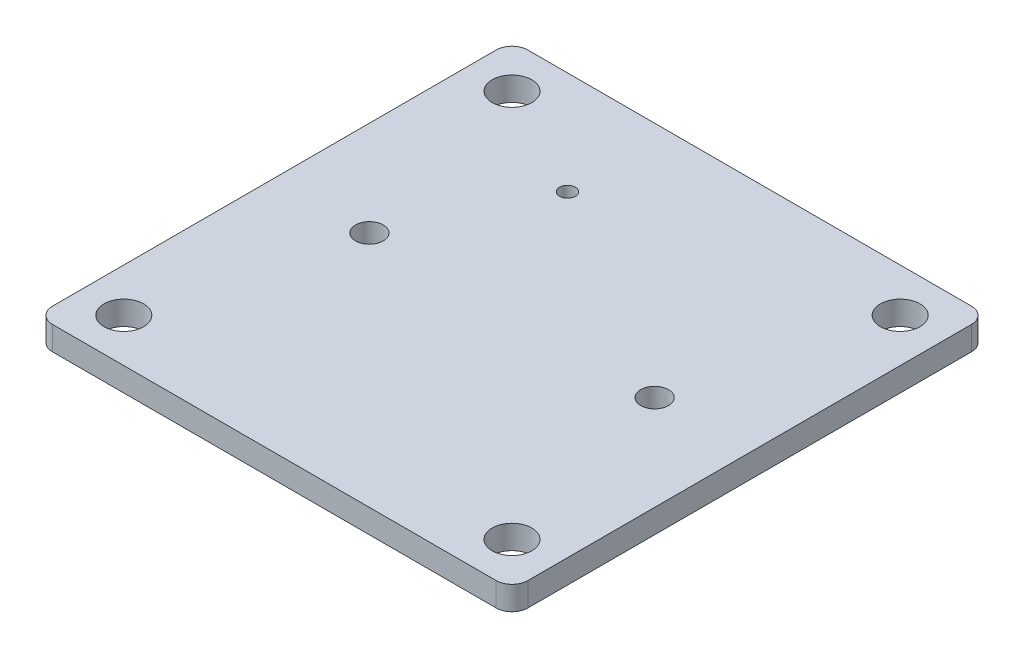
from build123d import *

# Parameters (mm, degrees)
SKETCH1_W           = 30
SKETCH1_H           = 30
SKETCH1_R           = 1.25
BOSS_EXTRUDE1_DEPTH = 1.5
FILLET1_R           = 1
SKETCH2_R           = 0.5
SKETCH2_R_2         = 0.875
CUT_EXTRUDE1_DEPTH  = 2.5


with BuildPart() as part:
    # Sketch1 → Boss-Extrude1 (new body)
    with BuildSketch(Plane(origin=(0, 0, 0), x_dir=(1, 0, 0), z_dir=(0, 1, 0))):
        Rectangle(SKETCH1_W, SKETCH1_H)
        with Locations((-12.25, 12.25)):
            Circle(SKETCH1_R, mode=Mode.SUBTRACT)
        with Locations((12.25, 12.25)):
            Circle(SKETCH1_R, mode=Mode.SUBTRACT)
        with Locations((12.25, -12.25)):
            Circle(SKETCH1_R, mode=Mode.SUBTRACT)
        with Locations((-12.25, -12.25)):
            Circle(SKETCH1_R, mode=Mode.SUBTRACT)
    extrude(amount=BOSS_EXTRUDE1_DEPTH)

    # Fillet1
    fillet1_edges = [part.edges().sort_by_distance(p)[0] for p in [
        (-15, 0.75, -15),
        (15, 0.75, -15),
        (15, 0.75, 15),
        (-15, 0.75, 15),
    ]]
    fillet(fillet1_edges, radius=FILLET1_R)

    # Sketch2 → Cut-Extrude1 (cut, through all)
    with BuildSketch(Plane(origin=(0, 1.5, 0), x_dir=(1, 0, 0), z_dir=(0, 1, 0))):
        with Locations((-5, 8.5)):
            Circle(SKETCH2_R)
        with Locations((-9, 0)):
            Circle(SKETCH2_R_2)
        with Locations((9, 0)):
            Circle(SKETCH2_R_2)
    extrude(amount=-CUT_EXTRUDE1_DEPTH, mode=Mode.SUBTRACT)


solid = part.part
